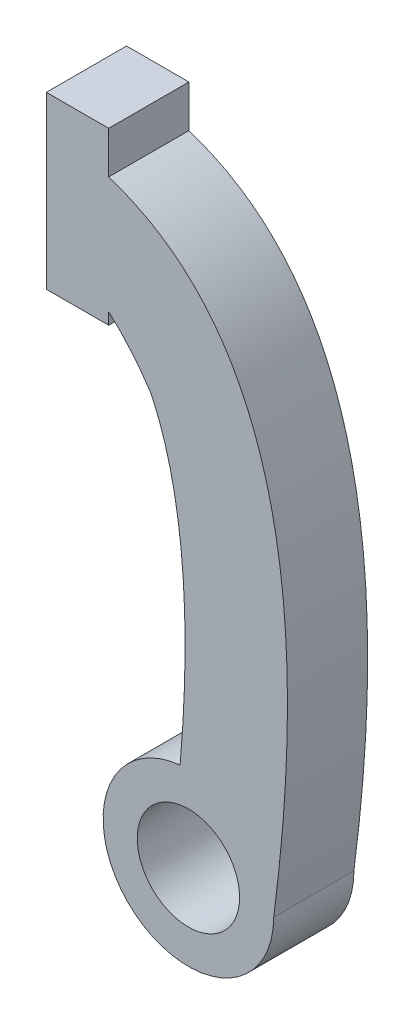
from build123d import *

# Parameters (mm, degrees)
SKETCH1_R           = 50
SKETCH1_R_2         = 30
BOSS_EXTRUDE1_DEPTH = 47


with BuildPart() as part:
    # Sketch1 → Boss-Extrude1 (new body)
    with BuildSketch(Plane.XY):
        with BuildLine():
            Line((-46.727102691, 252.119188355), (-46.727102691, 258.937140002))
            add(Edge.make_bspline(
                [(-22.082294652, 230.189836254), (-33.358154649, 247.131709382), (-46.727102689, 258.937140004)],
                knots=[0, 0, 0, 0.202133658, 0.202133658, 0.202133658], degree=2))
            add(Edge.make_bspline(
                [(-4.870036741, 49.762262229), (-4.393775013, 55.181886992), (-3.493820314, 66.662022051), (-2.529366378, 83.59139057), (-1.982320476, 100.516724073), (-1.858789362, 121.992140621), (-2.814978943, 146.760764163), (-5.156886221, 168.679611703), (-7.775671314, 184.458623381), (-10.08390129, 195.406366158), (-12.704291898, 205.462363583), (-15.117675621, 213.09980662), (-17.165967371, 218.768249548), (-18.756253721, 222.802063426), (-20.120456476, 225.981036836), (-21.236527654, 228.424580455), (-21.795733048, 229.59981685), (-22.082294652, 230.189836254)],
                knots=[0.06256779, 0.06256779, 0.06256779, 0.06256779, 0.087876155, 0.117168207, 0.146460259, 0.17575231, 0.234336414, 0.292920517, 0.322212569, 0.35150462, 0.380796672, 0.410088724, 0.42473475, 0.439380776, 0.454026801, 0.461349814, 0.468672827, 0.468672827, 0.468672827, 0.468672827], degree=3))
            ThreePointArc((-4.870036741, 49.762262229), (33.589419189, 37.037155918), (50, 0))
            add(Edge.make_bspline(
                [(50, 0), (87.107306859, 283.791217757), (-46.727102691, 327.431264092)],
                knots=[0, 0, 0, 0.770439733, 0.770439733, 0.770439733], degree=2))
            Line((-46.727102691, 327.431264091), (-46.727102691, 352.119188355))
            Line((-46.727102691, 352.119188355), (-83.272897309, 352.119188355))
            Line((-83.272897309, 352.119188355), (-83.272897309, 252.119188355))
            Line((-83.272897309, 252.119188355), (-46.727102691, 252.119188355))
        make_face()
        Circle(SKETCH1_R)
        Circle(SKETCH1_R_2, mode=Mode.SUBTRACT)
    extrude(amount=BOSS_EXTRUDE1_DEPTH)


solid = part.part
